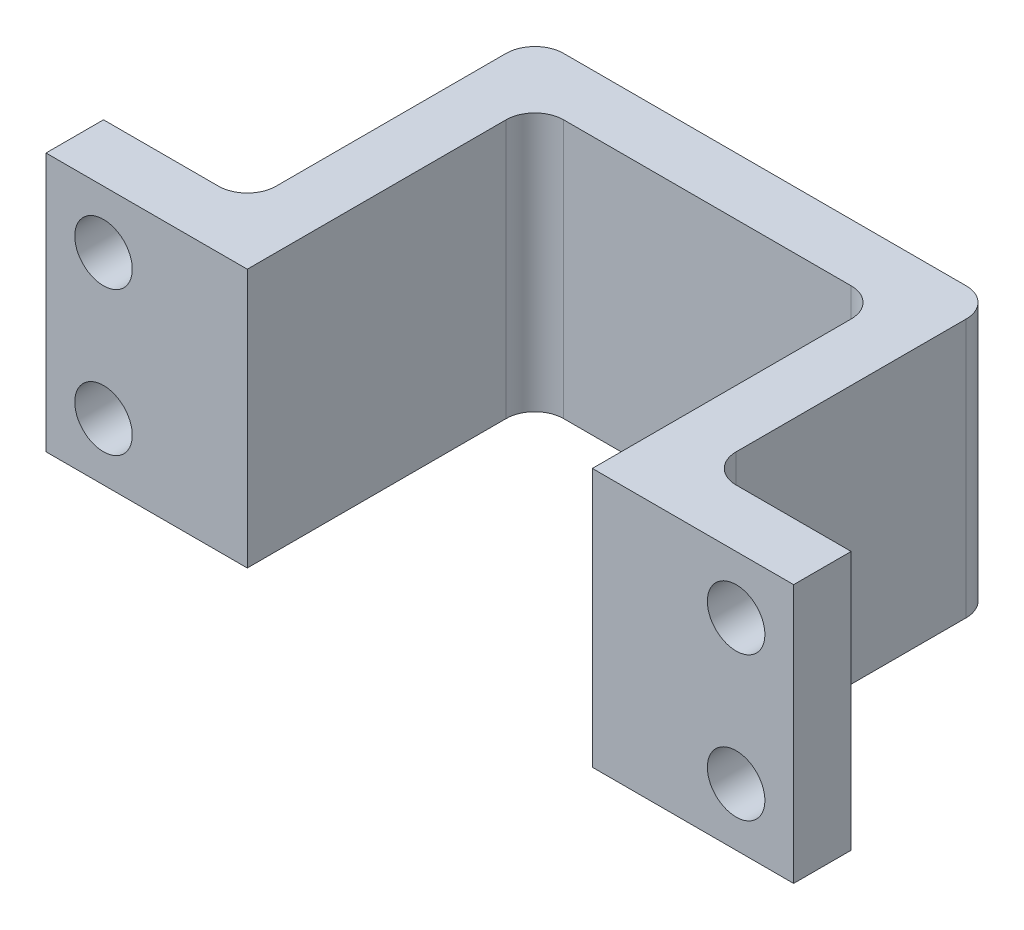
from build123d import *

# Parameters (mm, degrees)
BOSS_EXTRUDE1_DEPTH = 9
SKETCH2_R           = 1
CUT_EXTRUDE1_DEPTH  = 9


with BuildPart() as part:
    # Sketch1 → Boss-Extrude1 (new body)
    with BuildSketch(Plane(origin=(0, 0, 0), x_dir=(1, 0, 0), z_dir=(0, 1, 0))):
        with BuildLine():
            Line((12, 0), (13.31838565, 0))
            Line((13.31838565, 0), (19, 0))
            Line((19, 0), (19, 2))
            Line((19, 2), (15, 2))
            ThreePointArc((15, 2), (14.292893219, 2.292893219), (14, 3))
            Line((14, 3), (14, 11))
            ThreePointArc((14, 11), (13.707106781, 11.707106781), (13, 12))
            Line((13, 12), (-1, 12))
            ThreePointArc((-1, 12), (-1.707106781, 11.707106781), (-2, 11))
            Line((-2, 11), (-2, 3))
            ThreePointArc((-2, 3), (-2.292893219, 2.292893219), (-3, 2))
            Line((-3, 2), (-7, 2))
            Line((-7, 2), (-7, 0))
            Line((-7, 0), (-0.237668161, 0))
            Line((-0.237668161, 0), (0, 0))
            Line((0, 0), (0, 9))
            ThreePointArc((0, 9), (0.292893219, 9.707106781), (1, 10))
            Line((1, 10), (11, 10))
            ThreePointArc((11, 10), (11.707106781, 9.707106781), (12, 9))
            Line((12, 9), (12, 0))
        make_face()
    extrude(amount=BOSS_EXTRUDE1_DEPTH)

    # Sketch2 → Cut-Extrude1 (cut)
    with BuildSketch(Plane(origin=(0, 0, -2), x_dir=(-1, 0, 0), z_dir=(0, 0, -1))):
        with Locations((-17, 7)):
            Circle(SKETCH2_R)
        with Locations((5, 7)):
            Circle(SKETCH2_R)
        with Locations((-17, 2)):
            Circle(SKETCH2_R)
        with Locations((5, 2)):
            Circle(SKETCH2_R)
    extrude(amount=-CUT_EXTRUDE1_DEPTH, mode=Mode.SUBTRACT)


solid = part.part
